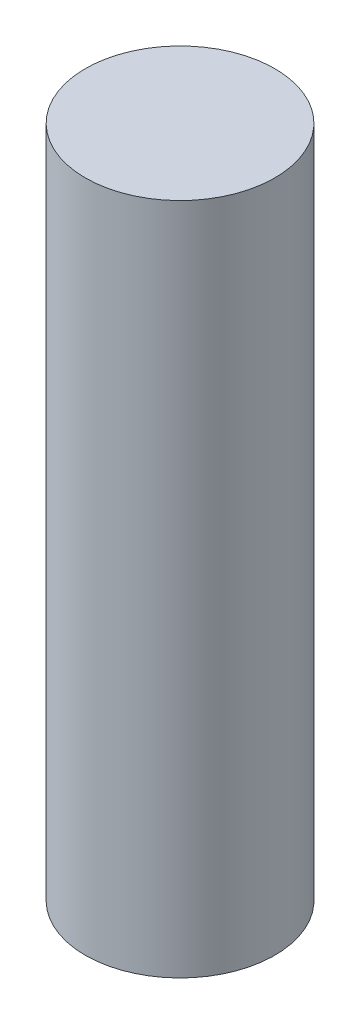
from build123d import *

# Parameters (mm, degrees)
SKETCH1_R           = 9.15
BOSS_EXTRUDE1_DEPTH = 65.05


with BuildPart() as part:
    # Sketch1 → Boss-Extrude1 (new body)
    with BuildSketch(Plane(origin=(0, 0, 0), x_dir=(1, 0, 0), z_dir=(0, 1, 0))):
        Circle(SKETCH1_R)
    extrude(amount=BOSS_EXTRUDE1_DEPTH)


solid = part.part
